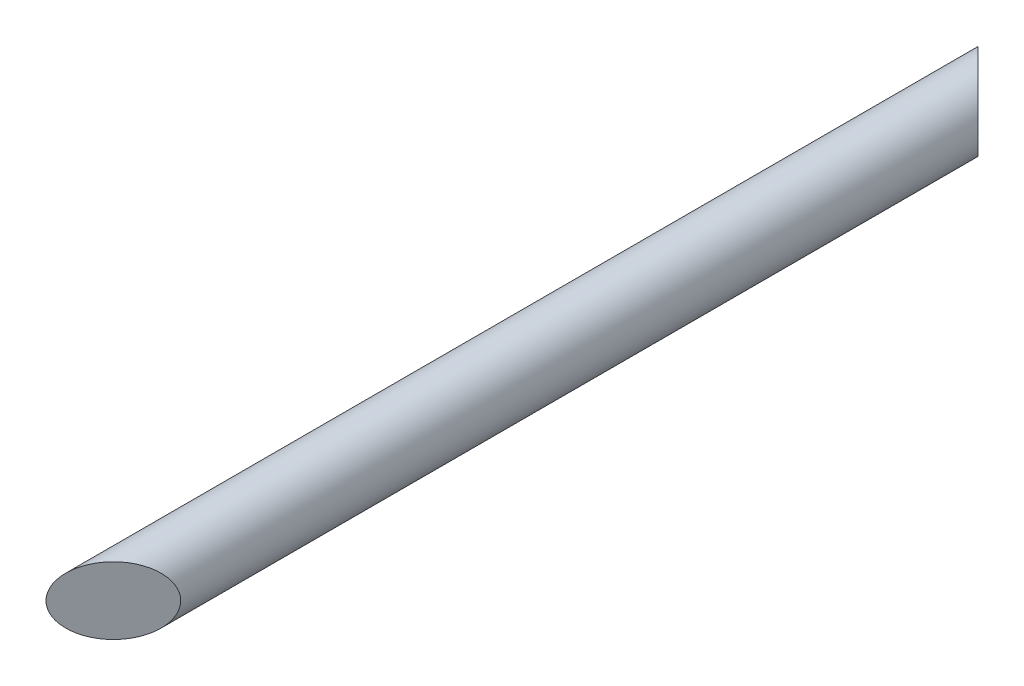
from build123d import *

# Parameters (mm, degrees)
SKETCH1_R           = 30
BOSS_EXTRUDE2_DEPTH = 830
CUT_EXTRUDE4_DEPTH  = 70
CUT_EXTRUDE5_DEPTH  = 70


with BuildPart() as part:
    # Sketch1 → Boss-Extrude2 (new body)
    with BuildSketch(Plane.XY):
        Circle(SKETCH1_R)
    extrude(amount=BOSS_EXTRUDE2_DEPTH)

    # Sketch3 → Cut-Extrude4 (cut)
    with BuildSketch(Plane(origin=(0, 40, 0), x_dir=(1, 0, 0), z_dir=(0, 1, 0))):
        Polygon((-30, 0), (30, -60), (30, 0), align=None)
    extrude(amount=-CUT_EXTRUDE4_DEPTH, mode=Mode.SUBTRACT)

    # Sketch4 → Cut-Extrude5 (cut)
    with BuildSketch(Plane(origin=(0, 40, 0), x_dir=(1, 0, 0), z_dir=(0, 1, 0))):
        Polygon((-30, -830), (30, -830), (30, -770), align=None)
    extrude(amount=-CUT_EXTRUDE5_DEPTH, mode=Mode.SUBTRACT)


solid = part.part
